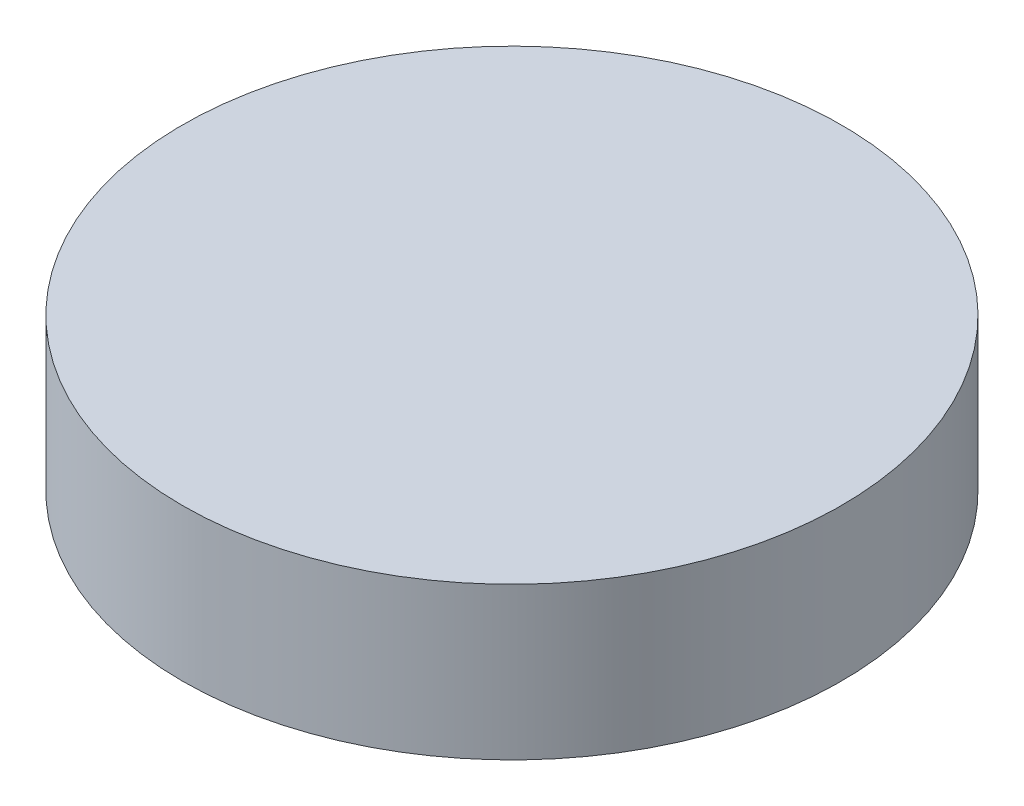
from build123d import *

# Parameters (mm, degrees)
SKETCH1_R      = 65
EXTRUDE1_DEPTH = 30


with BuildPart() as part:
    # Sketch1 → Extrude1 (new body)
    with BuildSketch(Plane(origin=(0, 0, 0), x_dir=(1, 0, 0), z_dir=(0, 1, 0))):
        with Locations(Location((0, 0, 0), (0, 0, 270))):  # turned: the seam where the file's is
            Circle(SKETCH1_R)
    extrude(amount=EXTRUDE1_DEPTH)


solid = part.part
